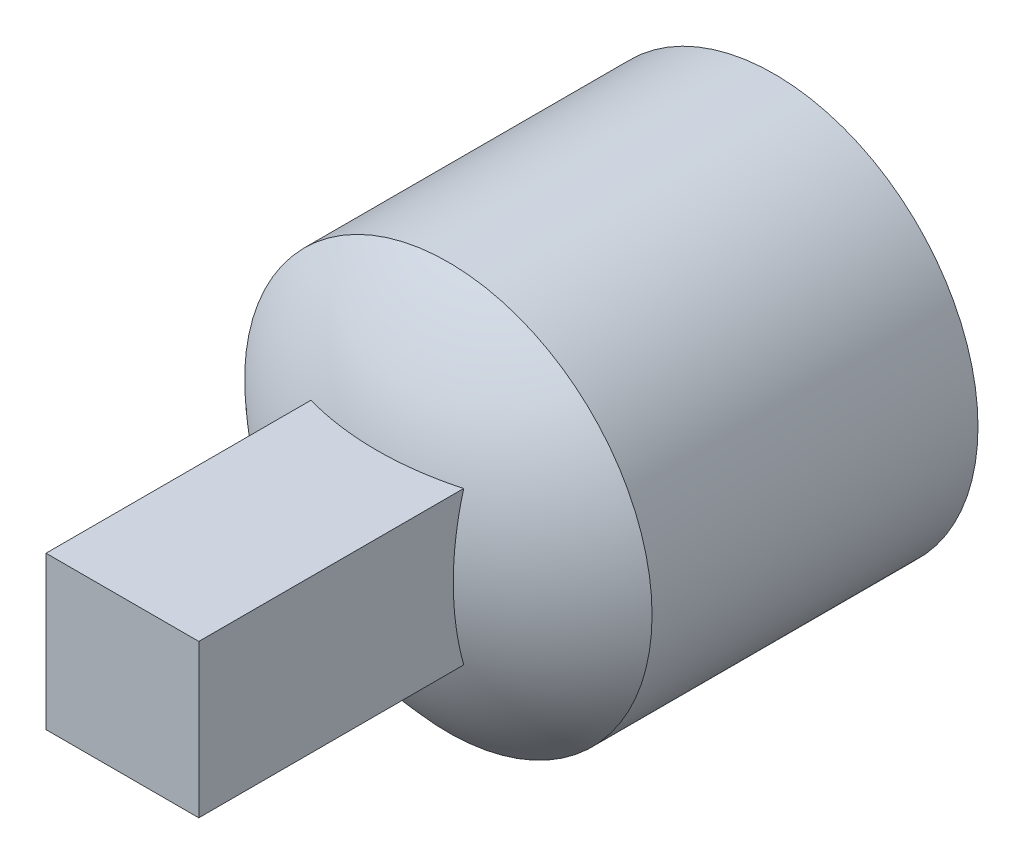
from build123d import *

# Parameters (mm, degrees)
SKETCH1_R           = 6.35
BOSS_EXTRUDE1_DEPTH = 10.16
DOME1_FACE_RADIUS   = 6.35
DOME1_HEIGHT        = 2.54
SKETCH3_W           = 3.81
SKETCH3_H           = 3.81
CUT_EXTRUDE1_DEPTH  = 7.62
SKETCH5_W           = 4.7625
SKETCH5_H           = 4.7625
BOSS_EXTRUDE2_DEPTH = 12.7
SKETCH6_R           = 1.5875
CUT_EXTRUDE2_DEPTH  = 12.7


with BuildPart() as part:
    # Sketch1 → Boss-Extrude1 (new body)
    with BuildSketch(Plane.XY):
        Circle(SKETCH1_R)
    extrude(amount=BOSS_EXTRUDE1_DEPTH)

    # Dome1: a dome of height H over a round flat face of radius A is a cap of a sphere of radius (A * A + H * H) / (2 * H)
    dome1_r = (DOME1_FACE_RADIUS * DOME1_FACE_RADIUS + DOME1_HEIGHT * DOME1_HEIGHT) / (2 * DOME1_HEIGHT)
    dome1_base = Plane((0, 0, 10.16), z_dir=(0, 0, 1))
    with Locations(dome1_base.offset(DOME1_HEIGHT - dome1_r)):
        dome1_ball = Sphere(dome1_r, mode=Mode.PRIVATE)
    add(split(dome1_ball, bisect_by=dome1_base, keep=Keep.TOP, mode=Mode.PRIVATE))

    # Sketch3 → Cut-Extrude1 (cut)
    with BuildSketch(Plane(origin=(0, 0, 7.62), x_dir=(-1, 0, 0), z_dir=(0, 0, -1))):
        Rectangle(SKETCH3_W, SKETCH3_H)
    extrude(amount=CUT_EXTRUDE1_DEPTH, mode=Mode.SUBTRACT)

    # Sketch5 → Boss-Extrude2 (add)
    with BuildSketch(Plane(origin=(0, 0, 7.62), x_dir=(-1, 0, 0), z_dir=(0, 0, -1))):
        Rectangle(SKETCH5_W, SKETCH5_H)
    extrude(amount=-BOSS_EXTRUDE2_DEPTH)

    # Sketch6 → Cut-Extrude2 (cut)
    with BuildSketch(Plane(origin=(-1.905, 0, 0), x_dir=(0, 0, -1), z_dir=(1, 0, 0))):
        with Locations((-3.96875, 0)):
            Circle(SKETCH6_R)
    extrude(amount=-CUT_EXTRUDE2_DEPTH, mode=Mode.SUBTRACT)


solid = part.part
